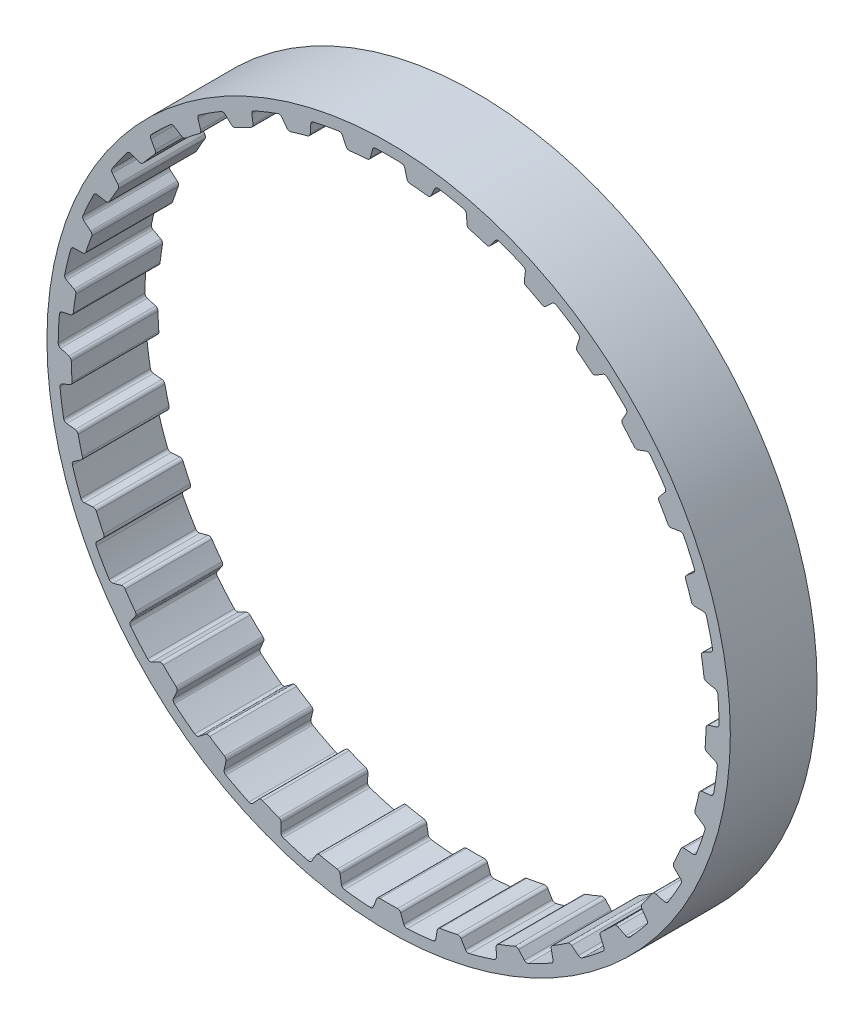
from build123d import *

# Parameters (mm, degrees)
SKETCH1_R           = 50.026419743
SKETCH1_R_2         = 46.470419743
BOSS_EXTRUDE1_DEPTH = 6.35
CUT_EXTRUDE1_DEPTH  = 6.35
CIRPATTERN1_COUNT   = 33


with BuildPart() as part:
    # Sketch1 → Boss-Extrude1 (new body, symmetric)
    with BuildSketch(Plane.XY):
        Circle(SKETCH1_R)
        Circle(SKETCH1_R_2, mode=Mode.SUBTRACT)
    extrude(amount=BOSS_EXTRUDE1_DEPTH, both=True)

    # Sketch3 → Cut-Extrude1 (cut, symmetric)
    with BuildSketch(Plane.XY):
        with BuildLine():
            Line((-3.135901383, 46.364491085), (3.135901383, 46.364491085))
            ThreePointArc((3.135901383, 46.364491085), (2.845947653, 46.480262725), (2.678464129, 46.743749929))
            Line((2.678464129, 46.743749929), (2.363305999, 47.958399928))
            ThreePointArc((2.363305999, 47.958399928), (2.190232104, 48.226455439), (1.891450561, 48.338428295))
            ThreePointArc((1.891450561, 48.338428295), (0, 48.375419743), (-1.891450561, 48.338428295))
            ThreePointArc((-1.891450561, 48.338428295), (-2.190232104, 48.226455439), (-2.363305999, 47.958399928))
            Line((-2.363305999, 47.958399928), (-2.678464129, 46.743749929))
            ThreePointArc((-2.678464129, 46.743749929), (-2.845947653, 46.480262725), (-3.135901383, 46.364491085))
        make_face()
    cut_extrude1 = extrude(amount=CUT_EXTRUDE1_DEPTH, both=True, mode=Mode.SUBTRACT)

    # CirPattern1: Cut-Extrude1 ×33 about axis
    cirpattern1_axis = Axis((0, 0, 0), (0, 0, 1))
    for i in range(1, CIRPATTERN1_COUNT):
        add(cut_extrude1.rotate(cirpattern1_axis, i * 360 / CIRPATTERN1_COUNT), mode=Mode.SUBTRACT)


solid = part.part
